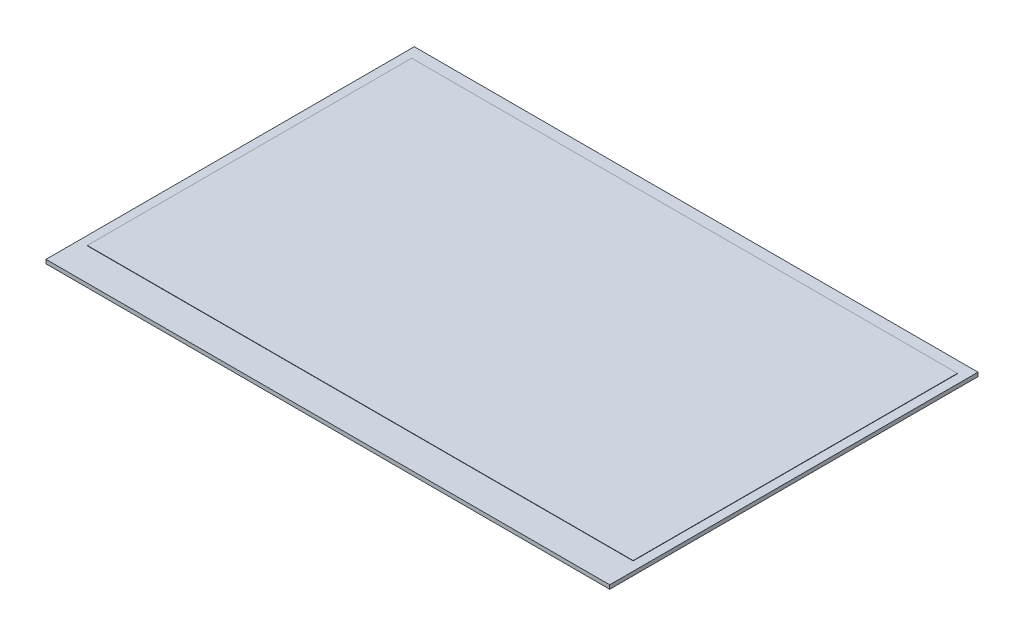
from build123d import *

# Parameters (mm, degrees)
SKETCH_1_W      = 170.2
SKETCH_1_H      = 111.2
EXTRUDE_1_DEPTH = 1.18
SKETCH_2_W      = 164.8
SKETCH_2_H      = 97.92
EXTRUDE_2_DEPTH = 0.1


with BuildPart() as part:
    # 草圖1 → 填料-伸長1 (new body)
    with BuildSketch(Plane(origin=(0, 0, 0), x_dir=(1, 0, 0), z_dir=(0, 1, 0))):
        Rectangle(SKETCH_1_W, SKETCH_1_H)
    extrude(amount=EXTRUDE_1_DEPTH)

    # 草圖2 → 填料-伸長2 (add)
    with BuildSketch(Plane(origin=(0, 1.18, 0), x_dir=(1, 0, 0), z_dir=(0, 1, 0))):
        with Locations((0, 3.14)):
            Rectangle(SKETCH_2_W, SKETCH_2_H)
    extrude(amount=EXTRUDE_2_DEPTH)


solid = part.part
